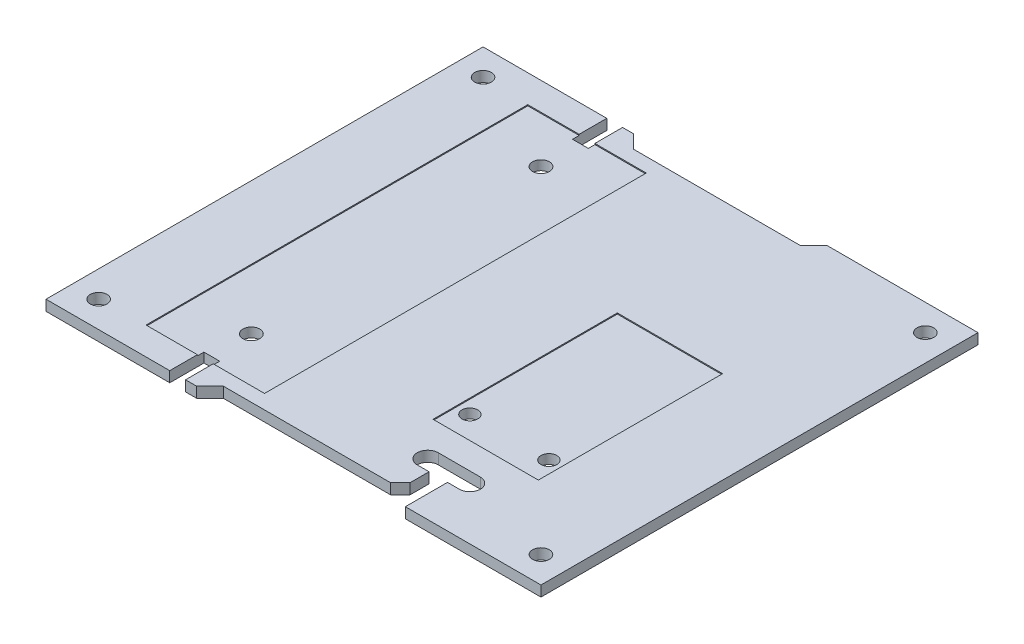
from build123d import *

# Parameters (mm, degrees)
SKETCH1_W           = 94
SKETCH1_H           = 83
SKETCH1_R           = 1.5875
BOSS_EXTRUDE1_DEPTH = 2
SKETCH2_R           = 1.6
SKETCH2_R_2         = 1.5
SKETCH2_W           = 3
SKETCH2_H           = 6.5
CUT_EXTRUDE1_DEPTH  = 3
SKETCH3_W           = 22.5
SKETCH3_H           = 72.5
SKETCH3_W_2         = 20
SKETCH3_H_2         = 35
CUT_EXTRUDE2_DEPTH  = 0.2
CUT_EXTRUDE3_DEPTH  = 3


with BuildPart() as part:
    # Sketch1 → Boss-Extrude1 (new body)
    with BuildSketch(Plane(origin=(0, 0, 0), x_dir=(1, 0, 0), z_dir=(0, 1, 0))):
        Rectangle(SKETCH1_W, SKETCH1_H)
        with Locations((-42, 36.5)):
            Circle(SKETCH1_R, mode=Mode.SUBTRACT)
        with Locations((42, 36.5)):
            Circle(SKETCH1_R, mode=Mode.SUBTRACT)
        with Locations((42, -36.5)):
            Circle(SKETCH1_R, mode=Mode.SUBTRACT)
        with Locations((-42, -36.5)):
            Circle(SKETCH1_R, mode=Mode.SUBTRACT)
    extrude(amount=BOSS_EXTRUDE1_DEPTH)

    # Sketch2 → Cut-Extrude1 (cut, through all)
    with BuildSketch(Plane(origin=(0, 2, 0), x_dir=(1, 0, 0), z_dir=(0, 1, 0))):
        with Locations((-22, -27.5)):
            Circle(SKETCH2_R)
        with Locations((-22, 27.5)):
            Circle(SKETCH2_R)
        with Locations((12, -20)):
            Circle(SKETCH2_R_2)
        with Locations((27, -20)):
            Circle(SKETCH2_R_2)
        with Locations((-22, 38.25)):
            Rectangle(SKETCH2_W, SKETCH2_H)
        with Locations((-22, -38.25)):
            Rectangle(SKETCH2_W, SKETCH2_H)
        with BuildLine():
            Line((15.5, -29.5), (23.5, -29.5))
            ThreePointArc((23.5, -29.5), (25.5, -31.5), (23.5, -33.5))
            Line((23.5, -33.5), (21.25, -33.5))
            Line((21.25, -33.5), (21.25, -41.5))
            Line((21.25, -41.5), (17.75, -41.5))
            Line((17.75, -41.5), (17.75, -33.5))
            Line((17.75, -33.5), (15.5, -33.5))
            ThreePointArc((15.5, -33.5), (13.5, -31.5), (15.5, -29.5))
        make_face()
    extrude(amount=-CUT_EXTRUDE1_DEPTH, mode=Mode.SUBTRACT)

    # Sketch3 → Cut-Extrude2 (cut)
    with BuildSketch(Plane(origin=(0, 2, 0), x_dir=(1, 0, 0), z_dir=(0, 1, 0))):
        with Locations((-22, 0)):
            Rectangle(SKETCH3_W, SKETCH3_H)
        with Locations((19.5, -7)):
            Rectangle(SKETCH3_W_2, SKETCH3_H_2)
    extrude(amount=-CUT_EXTRUDE2_DEPTH, mode=Mode.SUBTRACT)

    # Sketch4 → Cut-Extrude3 (cut, through all)
    with BuildSketch(Plane(origin=(0, 2, 0), x_dir=(1, 0, 0), z_dir=(0, 1, 0))):
        Polygon((18.415, 41.5), (-18.415, 41.5), (-15.875, 38.96), (15.875, 38.96), align=None)
        Polygon((-15.875, -38.96), (-18.415, -41.5), (17.75, -41.5), (17.75, -37.085), (15.875, -38.96), align=None)
    extrude(amount=-CUT_EXTRUDE3_DEPTH, mode=Mode.SUBTRACT)


solid = part.part
